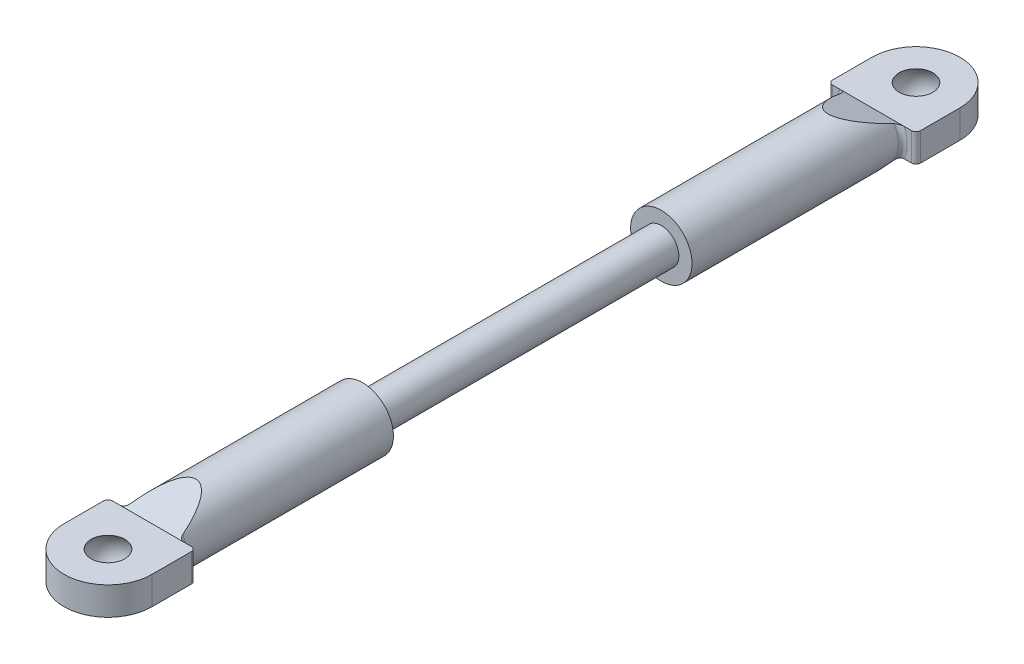
from build123d import *

# Parameters (mm, degrees)
SKETCH1_R                  = 2
SCREW_SECTION_DEPTH        = 17
SKETCH2_R                  = 3.5
BAR_SECTION_DEPTH          = 24
MOUNT_SECTION_DEPTH        = 1.6
BAR_TAPER_DEPTH            = 6
MOUNT_FILLET_R             = 0.5
MOUNT_FILLET_OF_MIRROR_2_R = 0.5


with BuildPart() as part:
    # Sketch1 → Screw Section (new body)
    with BuildSketch(Plane.XY):
        Circle(SKETCH1_R)
    screw_section = extrude(amount=SCREW_SECTION_DEPTH)

    # Sketch2 → Bar Section (add)
    with BuildSketch(Plane.XY.offset(17)):
        Circle(SKETCH2_R)
    bar_section = extrude(amount=BAR_SECTION_DEPTH)

    # Sketch3 → Mount Section (add, symmetric)
    with BuildSketch(Plane(origin=(0, 0, 0), x_dir=(1, 0, 0), z_dir=(0, 1, 0))):
        with BuildLine():
            Line((5, -41), (-5, -41))
            Line((-5, -41), (-5, -46))
            ThreePointArc((-5, -46), (0, -51), (5, -46))
            Line((5, -46), (5, -41))
        make_face()
    mount_section = extrude(amount=MOUNT_SECTION_DEPTH, both=True)

    # Sketch4 → Bar Taper (cut, symmetric)
    with BuildSketch(Plane(origin=(0, 0, 0), x_dir=(0, 0, -1), z_dir=(1, 0, 0))):
        Polygon((-36, -3.5), (-41, -1.6), (-41, -3.5), align=None)
        Polygon((-36, 3.5), (-41, 1.6), (-41, 3.5), align=None)
    bar_taper = extrude(amount=BAR_TAPER_DEPTH, both=True, mode=Mode.SUBTRACT)

    # Mount Fillet
    mount_fillet_edges = [part.edges().sort_by_distance(p)[0] for p in [
        (-5, 0, 41),
        (3.401842713, -0.823083322, 41),
        (-3.5, 0, 41),
        (5, 0, 41),
    ]]
    fillet(mount_fillet_edges, radius=MOUNT_FILLET_R)

    # Sketch6 → Ball Hole (revolve, cut)
    with BuildSketch(Plane(origin=(0, 0, 0), x_dir=(0, 0, -1), z_dir=(1, 0, 0))):
        with BuildLine():
            Line((-47.920937271, -1.6), (-46, -1.6))
            Line((-46, -1.6), (-46, 1.6))
            Line((-46, 1.6), (-47.920937271, 1.6))
            ThreePointArc((-47.920937271, 1.6), (-48.5, 0), (-47.920937271, -1.6))
        make_face()
    ball_hole = revolve(axis=Axis((0, -1.6, 46), (0, 1, 0)), mode=Mode.SUBTRACT)

    # Mirror 2: Screw Section, Bar Section, Mount Section, Bar Taper, Ball Hole across Front Plane
    add(screw_section.mirror(Plane.XY))
    add(bar_section.mirror(Plane.XY))
    add(mount_section.mirror(Plane.XY))
    add(bar_taper.mirror(Plane.XY), mode=Mode.SUBTRACT)
    add(ball_hole.mirror(Plane.XY), mode=Mode.SUBTRACT)

    # Mount Fillet of Mirror 2
    mount_fillet_of_mirror_2_edges = [part.edges().sort_by_distance(p)[0] for p in [
        (-5, 0, -41),
        (3.401842713, -0.823083322, -41),
        (-3.5, 0, -41),
        (5, 0, -41),
    ]]
    fillet(mount_fillet_of_mirror_2_edges, radius=MOUNT_FILLET_OF_MIRROR_2_R)


solid = part.part
